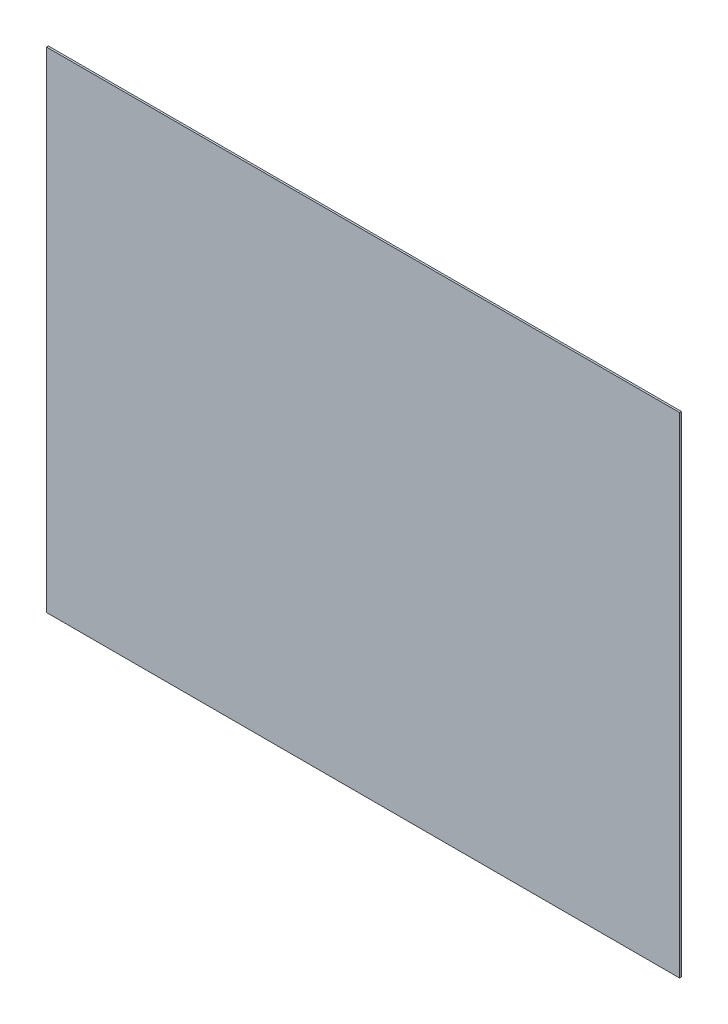
from build123d import *

# Parameters (mm, degrees)
SKETCH1_W           = 1066.8
SKETCH1_H           = 825.5
BOSS_EXTRUDE1_DEPTH = 3.175


with BuildPart() as part:
    # Sketch1 → Boss-Extrude1 (new body)
    with BuildSketch(Plane.XY):
        Rectangle(SKETCH1_W, SKETCH1_H)
    extrude(amount=BOSS_EXTRUDE1_DEPTH)


solid = part.part
